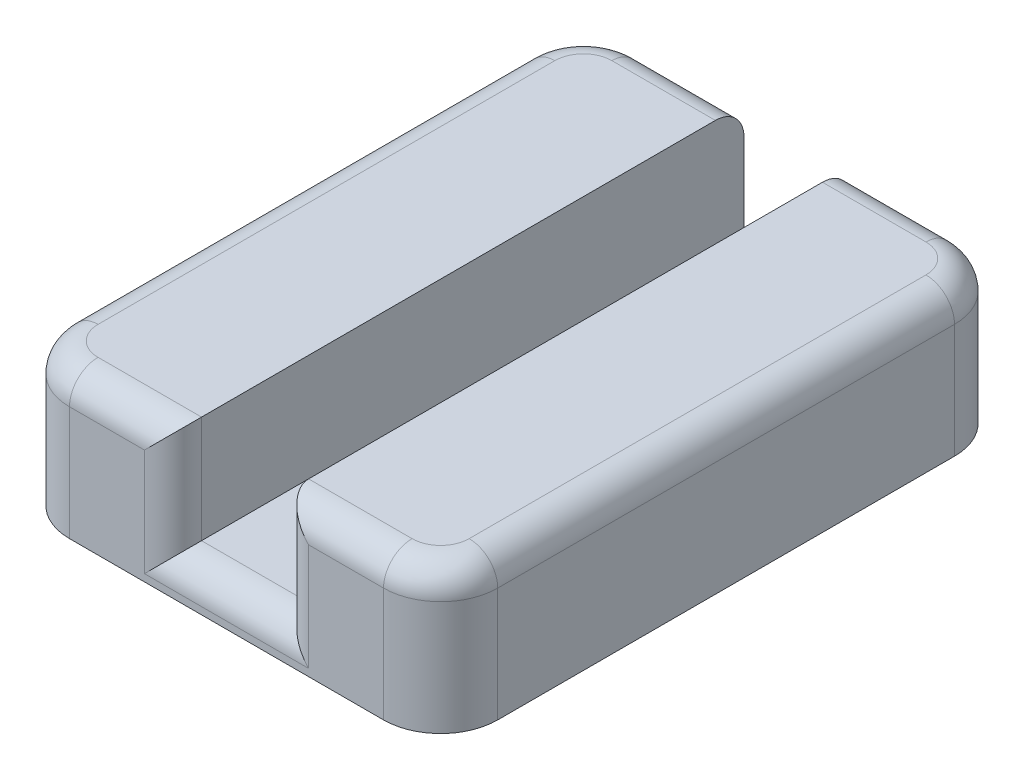
from build123d import *

# Parameters (mm, degrees)
BOSS_EXTRUDE1_DEPTH = 6.35
SKETCH2_W           = 4.7625
SKETCH2_H           = 19.05
CUT_EXTRUDE1_DEPTH  = 4.7625
FILLET1_R           = 1.27


with BuildPart() as part:
    # Sketch1 → Boss-Extrude1 (new body)
    with BuildSketch(Plane(origin=(0, 0, 0), x_dir=(1, 0, 0), z_dir=(0, 1, 0))):
        with BuildLine():
            Line((11.90625, 25.4), (16.51, 25.4))
            ThreePointArc((16.51, 25.4), (18.306051224, 24.656051224), (19.05, 22.86))
            Line((19.05, 22.86), (19.05, 2.54))
            ThreePointArc((19.05, 2.54), (18.306051224, 0.743948776), (16.51, 0))
            Line((16.51, 0), (2.54, 0))
            ThreePointArc((2.54, 0), (0.743948776, 0.743948776), (0, 2.54))
            Line((0, 2.54), (0, 22.86))
            ThreePointArc((0, 22.86), (0.743948776, 24.656051224), (2.54, 25.4))
            Line((2.54, 25.4), (7.14375, 25.4))
            Line((7.14375, 25.4), (7.14375, 19.05))
            Line((7.14375, 19.05), (11.90625, 19.05))
            Line((11.90625, 19.05), (11.90625, 25.4))
        make_face()
    extrude(amount=BOSS_EXTRUDE1_DEPTH)

    # Sketch2 → Cut-Extrude1 (cut)
    with BuildSketch(Plane(origin=(0, 6.35, 0), x_dir=(1, 0, 0), z_dir=(0, 1, 0))):
        with Locations((9.525, 9.525)):
            Rectangle(SKETCH2_W, SKETCH2_H)
    extrude(amount=-CUT_EXTRUDE1_DEPTH, mode=Mode.SUBTRACT)

    # Fillet1
    fillet1_edges = [part.edges().sort_by_distance(p)[0] for p in [
        (0.743948776, 6.35, -24.656051224),
        (4.841875, 6.35, -25.4),
        (14.208125, 6.35, -25.4),
        (14.208125, 6.35, 0),
        (18.306051224, 6.35, -24.656051224),
        (7.14375, 3.96875, 0),
        (9.525, 1.5875, -19.05),
        (9.525, 1.5875, 0),
        (11.90625, 3.96875, 0),
        (19.05, 6.35, -12.7),
        (18.306051224, 6.35, -0.743948776),
        (4.841875, 6.35, 0),
        (0.743948776, 6.35, -0.743948776),
        (0, 6.35, -12.7),
    ]]
    fillet(fillet1_edges, radius=FILLET1_R)


solid = part.part
